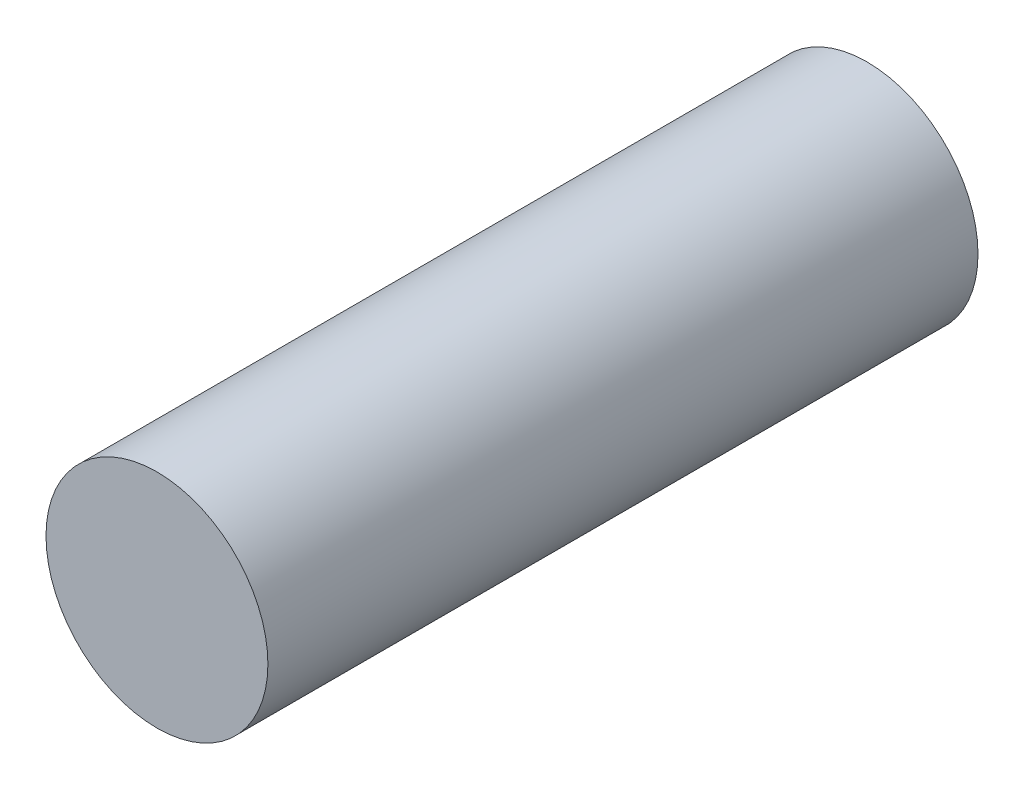
from build123d import *

# Parameters (mm, degrees)
SKETCH_1_R      = 5
EXTRUDE_1_DEPTH = 32


with BuildPart() as part:
    # 스케치1 → 보스-돌출1 (new body)
    with BuildSketch(Plane.XY):
        Circle(SKETCH_1_R)
    extrude(amount=EXTRUDE_1_DEPTH)


solid = part.part
